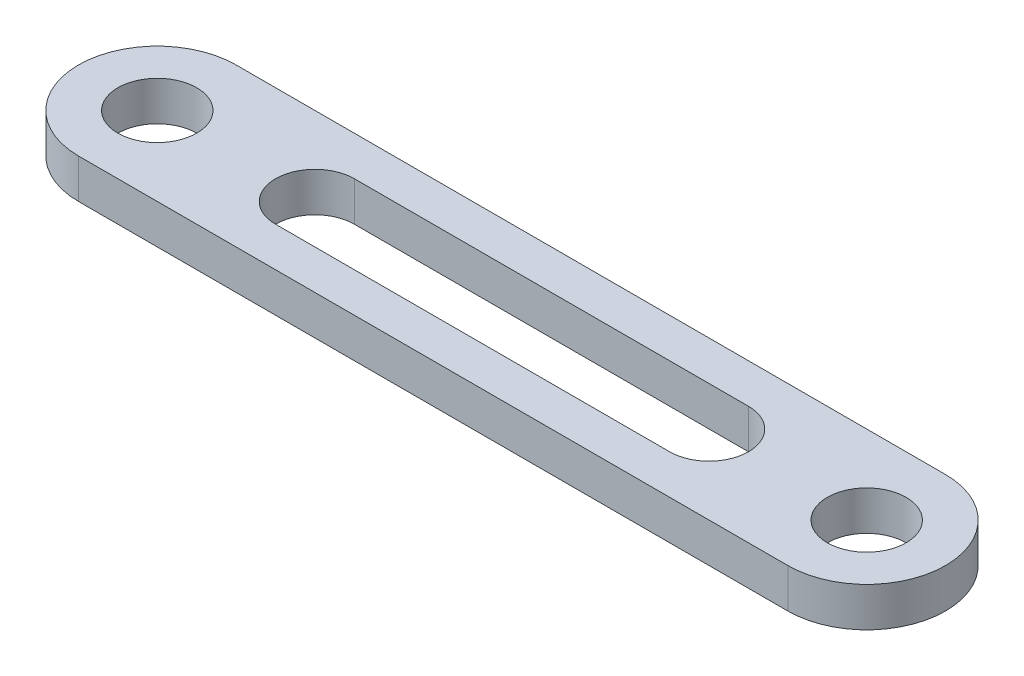
from build123d import *

# Parameters (mm, degrees)
SKETCH1_R           = 5
BOSS_EXTRUDE1_DEPTH = 5


with BuildPart() as part:
    # Sketch1 → Boss-Extrude1 (new body)
    with BuildSketch(Plane(origin=(0, 0, 0), x_dir=(1, 0, 0), z_dir=(0, 1, 0))):
        with BuildLine():
            Line((0, 10), (90, 10))
            ThreePointArc((90, 10), (100, 0), (90, -10))
            Line((90, -10), (0, -10))
            ThreePointArc((0, -10), (-10, 0), (0, 10))
        make_face()
        Circle(SKETCH1_R, mode=Mode.SUBTRACT)
        with Locations((90, 0)):
            Circle(SKETCH1_R, mode=Mode.SUBTRACT)
        with BuildLine():
            Line((20, 5), (70, 5))
            ThreePointArc((70, 5), (75, 0), (70, -5))
            Line((70, -5), (20, -5))
            ThreePointArc((20, -5), (15, 0), (20, 5))
        make_face(mode=Mode.SUBTRACT)
    extrude(amount=BOSS_EXTRUDE1_DEPTH)


solid = part.part
